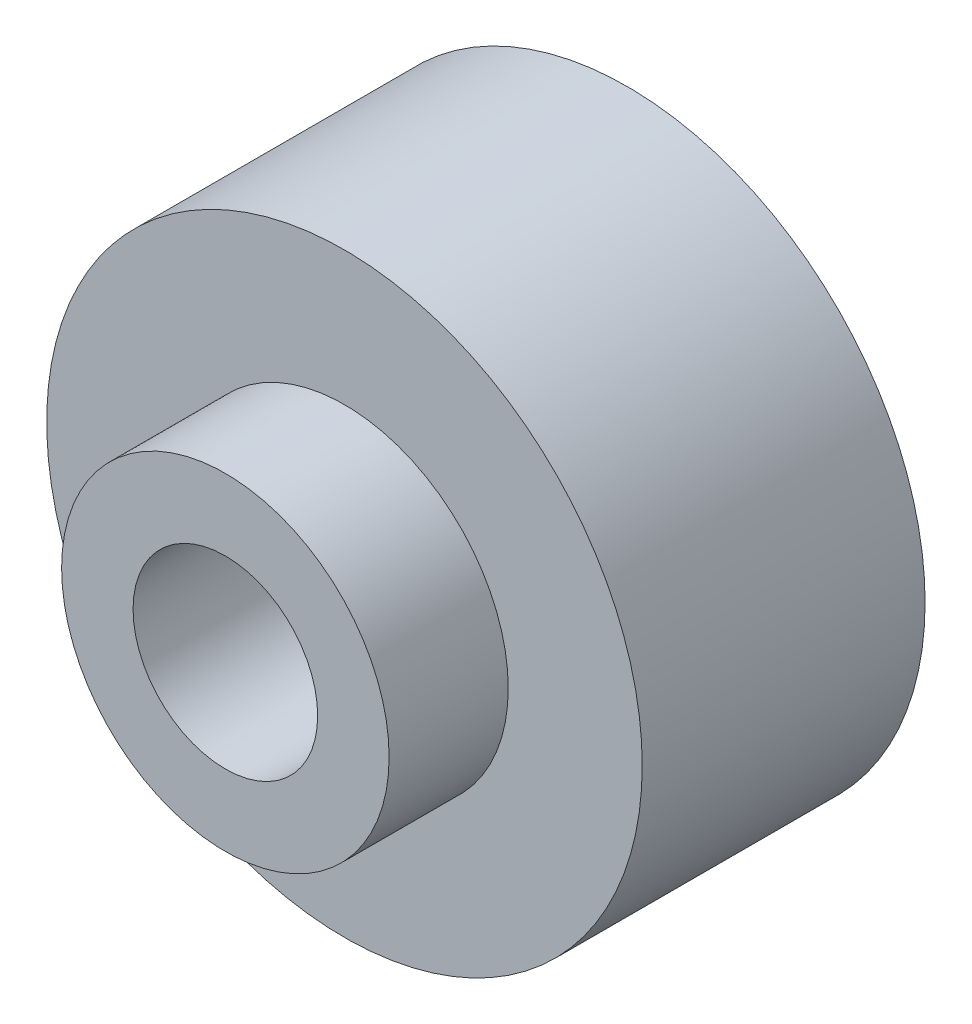
from build123d import *

# Parameters (mm, degrees)
SKETCH_1_R          = 5
SKETCH_1_R_2        = 1.55
EXTRUDE_1_DEPTH     = 4.75
SKETCH_2_R          = 2.75
SKETCH_2_R_2        = 1.55
EXTRUDE_2_DEPTH     = 2
SKETCH_3_R          = 3.5
SKETCH_3_R_2        = 1.55
CUT_EXTRUDE_1_DEPTH = 2


with BuildPart() as part:
    # 草图1 → 凸台-拉伸1 (new body)
    with BuildSketch(Plane.XY):
        Circle(SKETCH_1_R)
        Circle(SKETCH_1_R_2, mode=Mode.SUBTRACT)
    extrude(amount=EXTRUDE_1_DEPTH)

    # 草图2 → 凸台-拉伸2 (add)
    with BuildSketch(Plane.XY.offset(4.75)):
        Circle(SKETCH_2_R)
        Circle(SKETCH_2_R_2, mode=Mode.SUBTRACT)
    extrude(amount=EXTRUDE_2_DEPTH)

    # 草图3 → 切除-拉伸1 (cut)
    with BuildSketch(Plane(origin=(0, 0, 0), x_dir=(-1, 0, 0), z_dir=(0, 0, -1))):
        Circle(SKETCH_3_R)
        Circle(SKETCH_3_R_2, mode=Mode.SUBTRACT)
    extrude(amount=-CUT_EXTRUDE_1_DEPTH, mode=Mode.SUBTRACT)


solid = part.part
